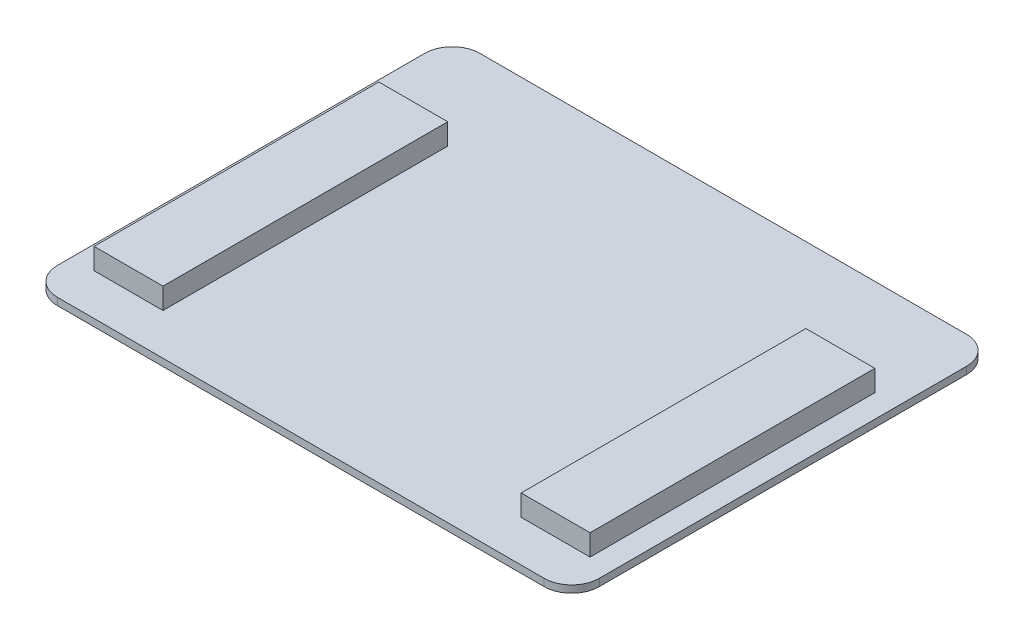
from build123d import *

# Parameters (mm, degrees)
SKETCH1_W           = 149.86
SKETCH1_H           = 116.84
BOSS_EXTRUDE1_DEPTH = 2
FILLET1_R           = 7.62
SKETCH2_W           = 19.05
SKETCH2_H           = 78.74
BOSS_EXTRUDE2_DEPTH = 5.842


with BuildPart() as part:
    # Sketch1 → Boss-Extrude1 (new body)
    with BuildSketch(Plane(origin=(0, 0, 0), x_dir=(1, 0, 0), z_dir=(0, 1, 0))):
        Rectangle(SKETCH1_W, SKETCH1_H)
    extrude(amount=BOSS_EXTRUDE1_DEPTH)

    # Fillet1
    fillet1_edges = [part.edges().sort_by_distance(p)[0] for p in [
        (-74.93, 1, -58.42),
        (74.93, 1, -58.42),
        (74.93, 1, 58.42),
        (-74.93, 1, 58.42),
    ]]
    fillet(fillet1_edges, radius=FILLET1_R)

    # Sketch2 → Boss-Extrude2 (add)
    with BuildSketch(Plane(origin=(0, 2, 0), x_dir=(1, 0, 0), z_dir=(0, 1, 0))):
        with Locations((59.055, -7.62)):
            Rectangle(SKETCH2_W, SKETCH2_H)
    boss_extrude2 = extrude(amount=BOSS_EXTRUDE2_DEPTH)

    # Mirror1: Boss-Extrude2 across plane
    add(boss_extrude2.mirror(Plane(origin=(0, 0, 0), x_dir=(0, 0, 1), z_dir=(1, 0, 0))))


solid = part.part
